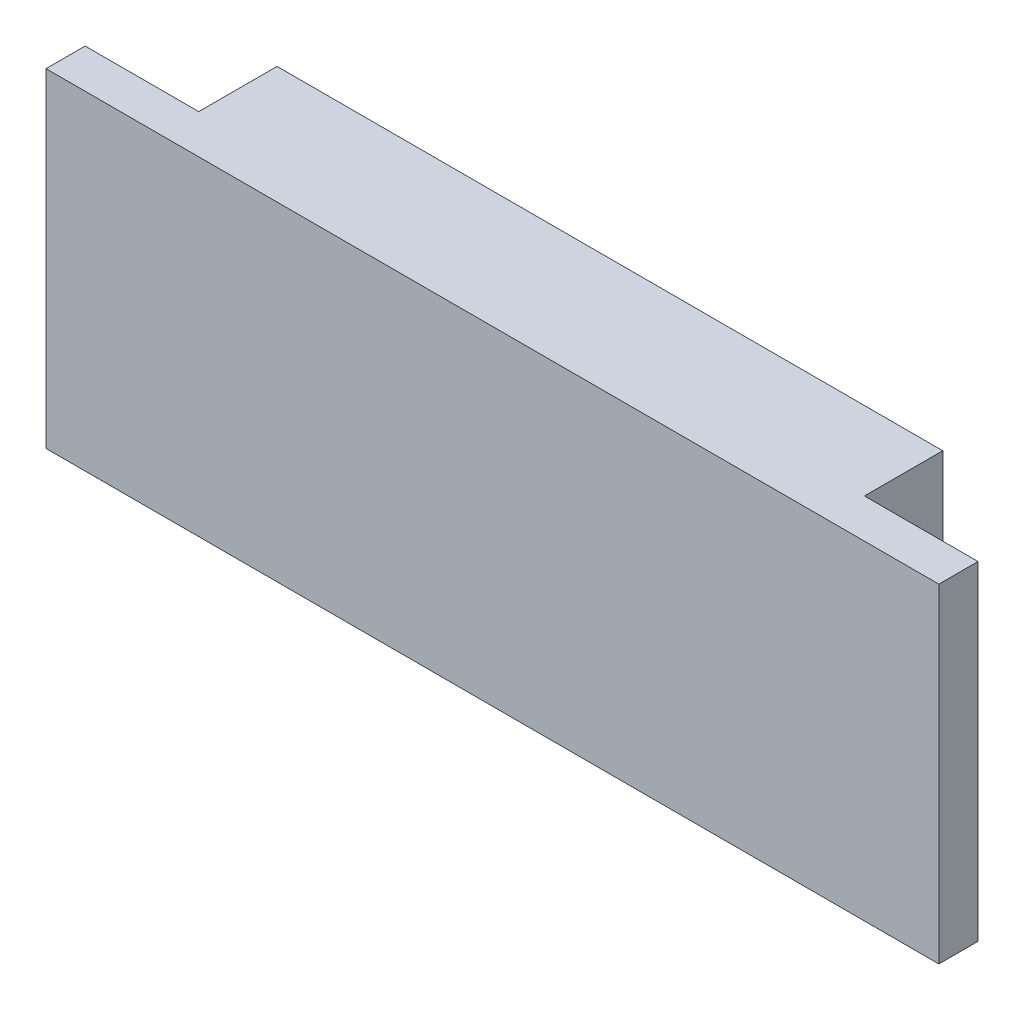
from build123d import *

# Parameters (mm, degrees)
SKETCH1_W           = 57
SKETCH1_H           = 21
BOSS_EXTRUDE1_DEPTH = 2.5
SKETCH2_W           = 42.5
SKETCH2_H           = 21
BOSS_EXTRUDE2_DEPTH = 5


with BuildPart() as part:
    # Sketch1 → Boss-Extrude1 (new body)
    with BuildSketch(Plane.XY):
        Rectangle(SKETCH1_W, SKETCH1_H)
    extrude(amount=BOSS_EXTRUDE1_DEPTH)

    # Sketch2 → Boss-Extrude2 (add)
    with BuildSketch(Plane(origin=(0, 0, 0), x_dir=(-1, 0, 0), z_dir=(0, 0, -1))):
        Rectangle(SKETCH2_W, SKETCH2_H)
    extrude(amount=BOSS_EXTRUDE2_DEPTH)


solid = part.part
